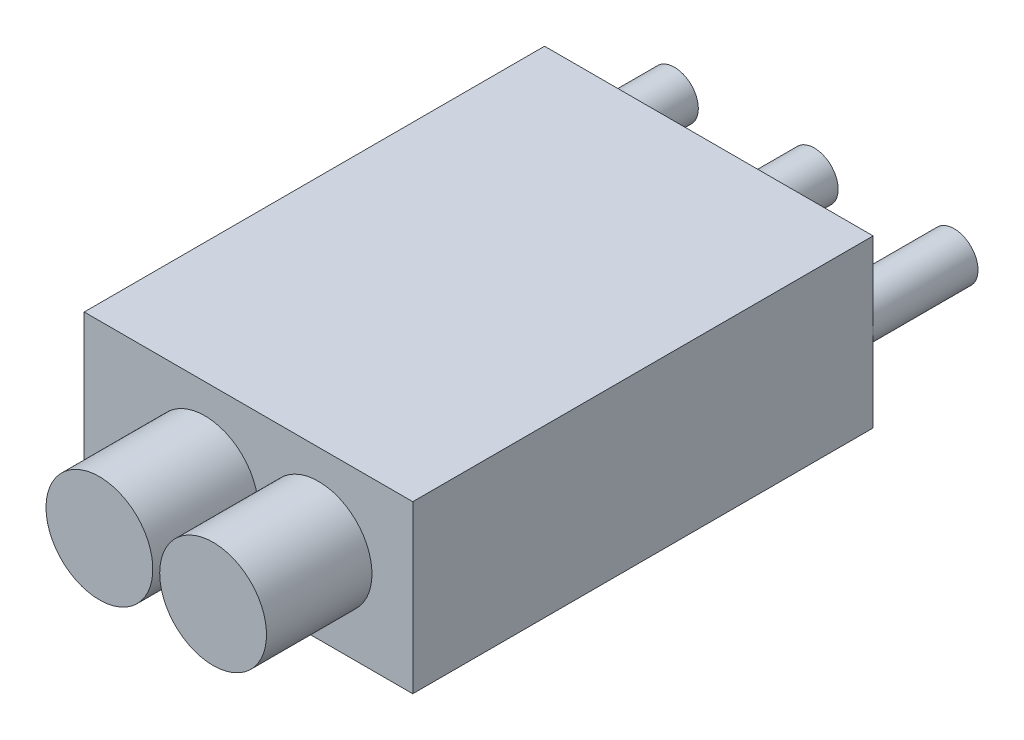
from build123d import *

# Parameters (mm, degrees)
SKETCH5_W           = 31.16
SKETCH5_H           = 43.66
BOSS_EXTRUDE2_DEPTH = 15.78
BOSS_EXTRUDE3_START = 21.83
SKETCH6_R           = 5.065
BOSS_EXTRUDE3_DEPTH = 10
SKETCH7_R           = 2.265
BOSS_EXTRUDE4_DEPTH = 10


with BuildPart() as part:
    # Sketch5 → Boss-Extrude2 (new body)
    with BuildSketch(Plane(origin=(0, 0, 0), x_dir=(1, 0, 0), z_dir=(0, 1, 0))):
        Rectangle(SKETCH5_W, SKETCH5_H)
    extrude(amount=BOSS_EXTRUDE2_DEPTH)

    # Sketch6 → Boss-Extrude3 (add)
    with BuildSketch(Plane.XY.offset(BOSS_EXTRUDE3_START)):
        with Locations((-4.139755926, 7.914788958)):
            Circle(SKETCH6_R)
        with Locations((6.643440648, 7.914788958)):
            Circle(SKETCH6_R)
    extrude(amount=BOSS_EXTRUDE3_DEPTH)

    # Sketch7 → Boss-Extrude4 (add)
    with BuildSketch(Plane(origin=(0, 0, -21.83), x_dir=(-1, 0, 0), z_dir=(0, 0, -1))):
        with Locations((-13.262092339, 7.949599191)):
            Circle(SKETCH7_R)
        with Locations((0, 7.949599191)):
            Circle(SKETCH7_R)
        with Locations((13.262092339, 7.949599191)):
            Circle(SKETCH7_R)
    extrude(amount=BOSS_EXTRUDE4_DEPTH)


solid = part.part
